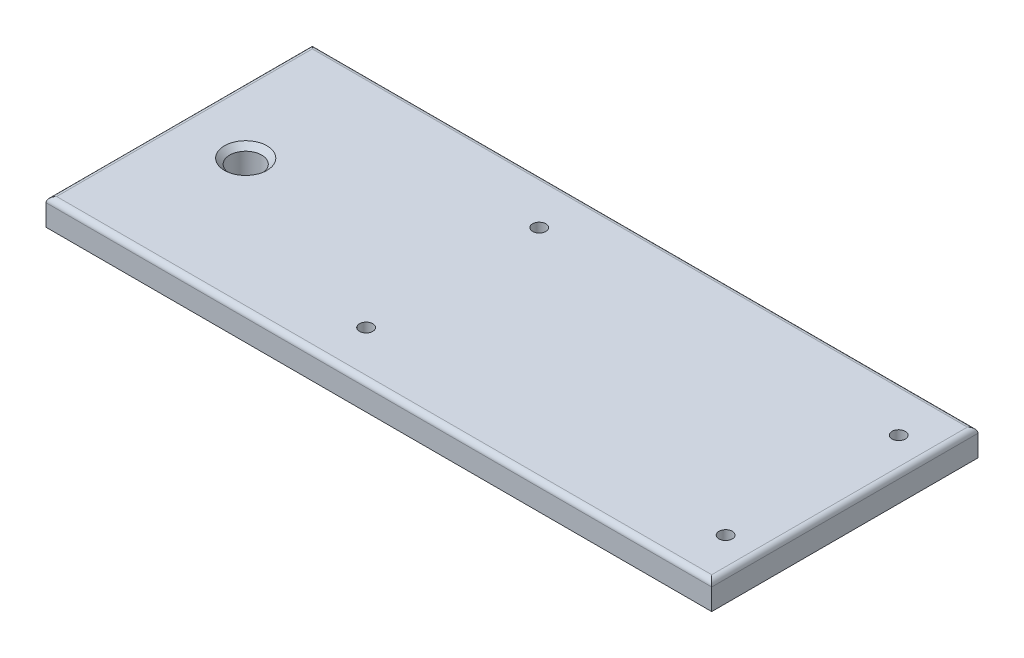
from build123d import *

# Parameters (mm, degrees)
SKETCH1_W           = 250
SKETCH1_H           = 100
BOSS_EXTRUDE1_DEPTH = 10
FILLET1_R           = 2
SKETCH2_R           = 6
CUT_EXTRUDE1_DEPTH  = 11
CHAMFER1_SIZE       = 2
SKETCH3_R           = 2.5
CUT_EXTRUDE2_DEPTH  = 11


with BuildPart() as part:
    # Sketch1 → Boss-Extrude1 (new body)
    with BuildSketch(Plane(origin=(0, 0, 0), x_dir=(1, 0, 0), z_dir=(0, 1, 0))):
        Rectangle(SKETCH1_W, SKETCH1_H)
    extrude(amount=BOSS_EXTRUDE1_DEPTH)

    # Fillet1
    fillet1_edges = [part.edges().sort_by_distance(p)[0] for p in [
        (125, 10, 0),
        (0, 10, -50),
        (-125, 10, 0),
        (0, 10, 50),
    ]]
    fillet(fillet1_edges, radius=FILLET1_R)

    # Sketch2 → Cut-Extrude1 (cut, through all)
    with BuildSketch(Plane(origin=(0, 10, 0), x_dir=(1, 0, 0), z_dir=(0, 1, 0))):
        with Locations((-100, 0)):
            Circle(SKETCH2_R)
    extrude(amount=-CUT_EXTRUDE1_DEPTH, mode=Mode.SUBTRACT)

    # Chamfer1
    chamfer1_edges = [part.edges().sort_by_distance(p)[0] for p in [
        (-106, 10, 0),
    ]]
    chamfer(chamfer1_edges, length=CHAMFER1_SIZE)

    # Sketch3 → Cut-Extrude2 (cut, through all)
    with BuildSketch(Plane(origin=(0, 10, 0), x_dir=(1, 0, 0), z_dir=(0, 1, 0))):
        with Locations((112.723846374, 32.5)):
            Circle(SKETCH3_R)
        with Locations((112.723846374, -32.5)):
            Circle(SKETCH3_R)
        with Locations((-22.276153626, 32.5)):
            Circle(SKETCH3_R)
        with Locations((-22.276153626, -32.5)):
            Circle(SKETCH3_R)
    extrude(amount=-CUT_EXTRUDE2_DEPTH, mode=Mode.SUBTRACT)


solid = part.part
